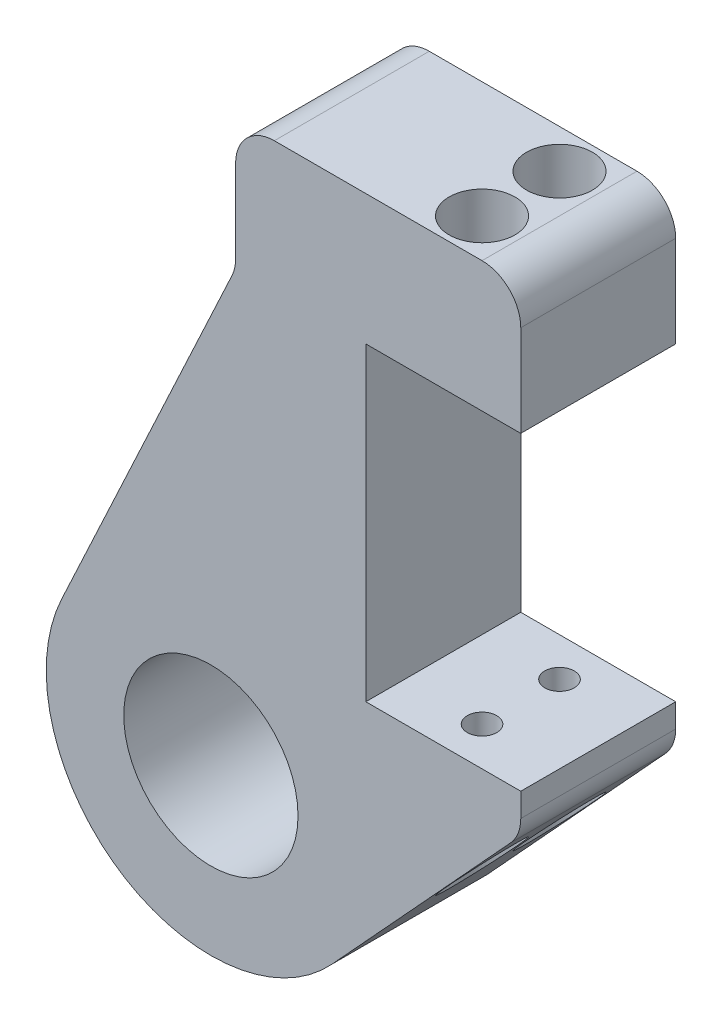
from build123d import *

# Parameters (mm, degrees)
SKETCH1_R               = 14.2875
INITIAL_PLATE_DEPTH     = 25.4
INITIAL_START           = -22.347989325
SKETCH3_R               = 2.413
INITIAL_BOLT_HOLE_DEPTH = 122.882919484
INITIAL_START_2         = -12.7
SKETCH3_3_R             = 5.3975
SKETCH3_3_R_2           = 2.413
INITIAL_HEAD_HOLE_DEPTH = 9.647989325
OTHER_START             = 90.807702
SKETCH3_4_R             = 5.3975
SKETCH3_4_R_2           = 2.413
OTHER_HEAD_HOLE_DEPTH   = 27.307702
MOUNTING_PATTERN_COUNT  = 2
MOUNTING_PATTERN_PITCH  = 12.7
FILLET1_R               = 6.35


with BuildPart() as part:
    # Sketch1 → Initial Plate (new body)
    with BuildSketch(Plane(origin=(0, -13.010095613, 793.75), x_dir=(1, 0, 0), z_dir=(0, 0, 1))):
        with BuildLine():
            Line((-3.175, -125.901852304), (-28.575, -125.901852304))
            Line((-28.575, -125.901852304), (-28.575, -75.101852304))
            Line((-28.575, -75.101852304), (-3.175, -75.101852304))
            Line((-3.175, -75.101852304), (-3.175, -53.753862978))
            Line((-3.175, -53.753862978), (-49.922989325, -53.753862978))
            Line((-49.922989325, -53.753862978), (-49.922989325, -75.101852304))
            Line((-49.922989325, -75.101852304), (-78.433981403, -136.243872124))
            ThreePointArc((-78.433981403, -136.243872124), (-68.984123144, -170.078089357), (-34.103220183, -165.909554179))
            Line((-34.103220183, -165.909554179), (-3.175, -132.251852304))
            Line((-3.175, -132.251852304), (-3.175, -125.901852304))
        make_face()
        with Locations((-53.975, -147.649282463)):
            Circle(SKETCH1_R, mode=Mode.SUBTRACT)
    extrude(amount=INITIAL_PLATE_DEPTH)

    # Sketch3 → Initial Bolt Hole (cut)
    with BuildSketch(Plane.XZ.offset(88.111947917).offset(INITIAL_START)):
        with Locations((-15.875, 800.1)):
            Circle(SKETCH3_R)
    initial_bolt_hole = extrude(amount=INITIAL_BOLT_HOLE_DEPTH, mode=Mode.SUBTRACT)

    # Sketch3_3 → Initial Head Hole (cut, through all)
    with BuildSketch(Plane.XZ.offset(88.111947917).offset(INITIAL_START_2)):
        with Locations((-15.875, 800.1)):
            Circle(SKETCH3_3_R)
        with Locations((-15.875, 800.1)):
            Circle(SKETCH3_3_R_2, mode=Mode.SUBTRACT)
    initial_head_hole = extrude(amount=-INITIAL_HEAD_HOLE_DEPTH, mode=Mode.SUBTRACT)

    # Sketch3_4 → Other Head Hole (cut)
    with BuildSketch(Plane.XZ.offset(88.111947917).offset(OTHER_START)):
        with Locations((-15.875, 800.1)):
            Circle(SKETCH3_4_R)
        with Locations((-15.875, 800.1)):
            Circle(SKETCH3_4_R_2, mode=Mode.SUBTRACT)
    other_head_hole = extrude(amount=-OTHER_HEAD_HOLE_DEPTH, mode=Mode.SUBTRACT)

    # Mounting Pattern: Initial Bolt Hole, Initial Head Hole, Other Head Hole ×2
    with Locations(*[(0, 0, i * MOUNTING_PATTERN_PITCH) for i in range(1, MOUNTING_PATTERN_COUNT)]):
        add(initial_bolt_hole, mode=Mode.SUBTRACT)
        add(initial_head_hole, mode=Mode.SUBTRACT)
        add(other_head_hole, mode=Mode.SUBTRACT)

    # Fillet1
    fillet1_edges = [part.edges().sort_by_distance(p)[0] for p in [
        (-3.175, -145.261947917, 806.45),
        (-49.922989325, -88.111947917, 806.45),
        (-49.922989325, -66.763958592, 806.45),
        (-3.175, -66.763958592, 806.45),
    ]]
    fillet(fillet1_edges, radius=FILLET1_R)


solid = part.part
